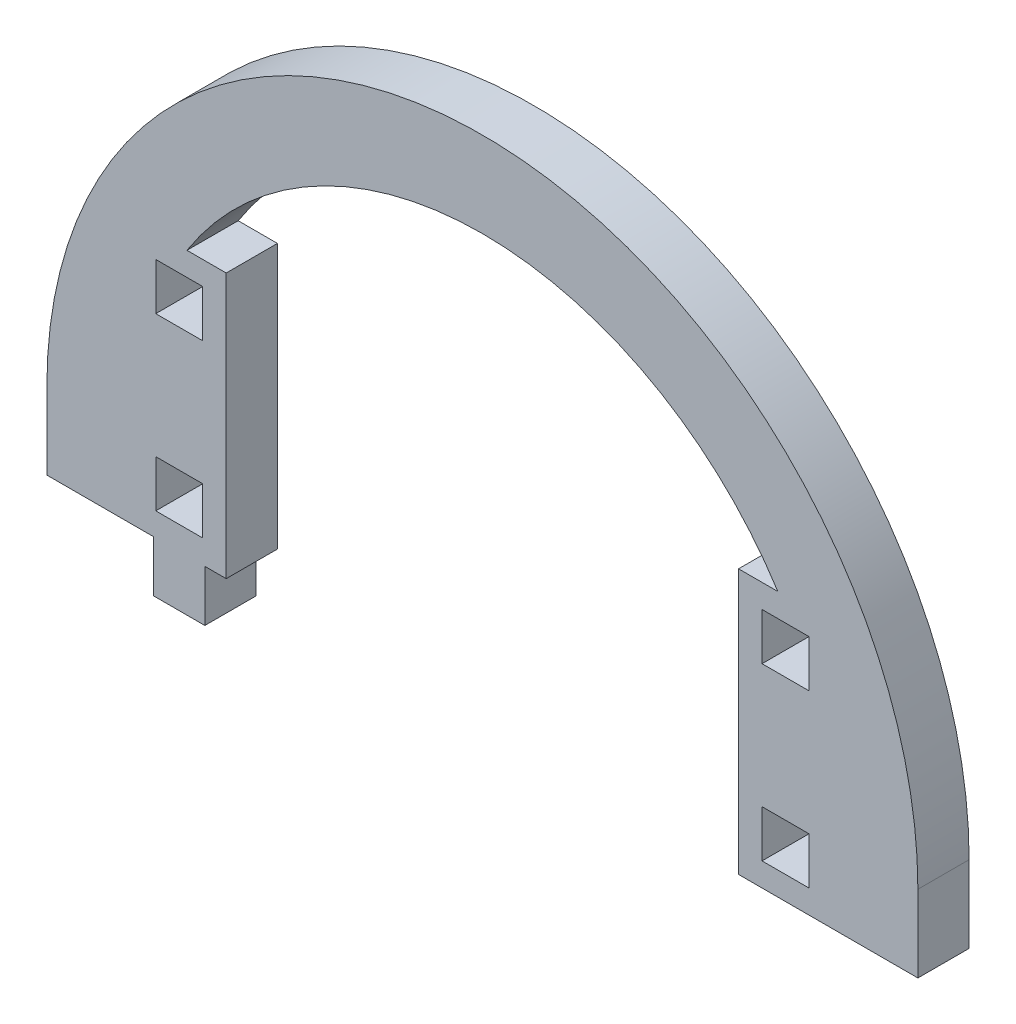
from build123d import *

# Parameters (mm, degrees)
MODEL_W             = 5.5
MODEL_H             = 5.5
BOSS_EXTRUDE1_DEPTH = 6


with BuildPart() as part:
    # Model → Boss-Extrude1 (new body)
    with BuildSketch(Plane.XY):
        with BuildLine():
            Line((3055.225160199, 1478.744697622), (3055.225160199, 1469.744697622))
            Line((3055.225160199, 1469.744697622), (3067.725160199, 1469.744697622))
            Line((3067.725160199, 1469.744697622), (3067.725160199, 1463.744697622))
            Line((3067.725160199, 1463.744697622), (3073.725160199, 1463.744697622))
            Line((3073.725160199, 1463.744697622), (3073.725160199, 1469.744697622))
            Line((3073.725160199, 1469.744697622), (3076.225160199, 1469.744697622))
            Line((3076.225160199, 1469.744697622), (3076.225160199, 1500.744697622))
            Line((3076.225160199, 1500.744697622), (3071.627472415, 1500.744697622))
            ThreePointArc((3071.627472415, 1500.744697622), (3106.225160199, 1519.744697622), (3140.822847983, 1500.744697622))
            Line((3140.822847983, 1500.744697622), (3136.225160199, 1500.744697622))
            Line((3136.225160199, 1500.744697622), (3136.225160199, 1469.744697622))
            Line((3136.225160199, 1469.744697622), (3147.225160199, 1469.744697622))
            Line((3147.225160199, 1469.744697622), (3157.225160199, 1469.744697622))
            Line((3157.225160199, 1469.744697622), (3157.225160199, 1478.744697622))
            ThreePointArc((3157.225160199, 1478.744697622), (3106.225160199, 1529.744697622), (3055.225160199, 1478.744697622))
        make_face()
        with Locations((3141.725160199, 1475.244697622)):
            Rectangle(MODEL_W, MODEL_H, mode=Mode.SUBTRACT)
        with Locations((3141.725160199, 1495.244697622)):
            Rectangle(MODEL_W, MODEL_H, mode=Mode.SUBTRACT)
        with Locations((3070.725160199, 1475.244697622)):
            Rectangle(MODEL_W, MODEL_H, mode=Mode.SUBTRACT)
        with Locations((3070.725160199, 1495.244697622)):
            Rectangle(MODEL_W, MODEL_H, mode=Mode.SUBTRACT)
    extrude(amount=BOSS_EXTRUDE1_DEPTH)


solid = part.part
